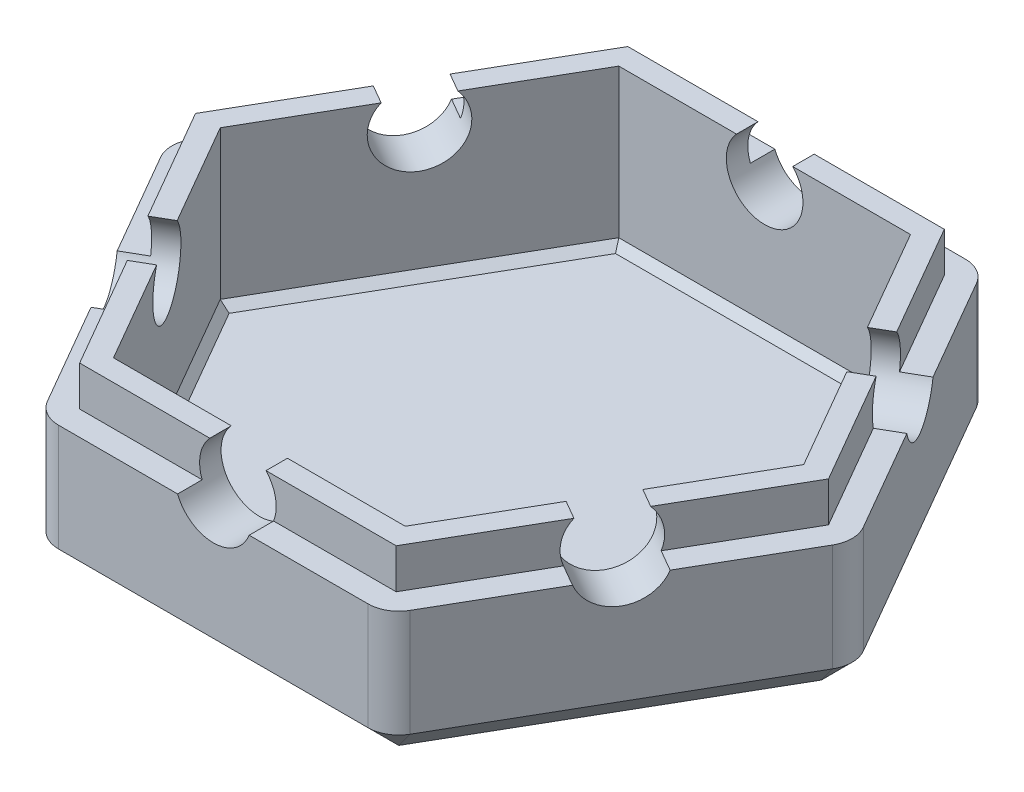
from build123d import *

# Parameters (mm, degrees)
BOSS_EXTRUDE1_START = -3.7
BOSS_EXTRUDE1_DEPTH = 10
CUT_EXTRUDE1_DEPTH  = 8.6
BOSS_EXTRUDE2_DEPTH = 1.6
FILLET1_R           = 2
CUT_EXTRUDE4_START  = -1
CUT_EXTRUDE4_DEPTH  = 1
CUT_EXTRUDE3_REACH  = 48.892
SKETCH4_R           = 2.5
CIRPATTERN1_COUNT   = 6
CHAMFER1_SIZE       = 0.5
CHAMFER2_SIZE       = 2


with BuildPart() as part:
    # Sketch1 → Boss-Extrude1 (new body)
    with BuildSketch(Plane(origin=(0, 0, 0), x_dir=(1, 0, 0), z_dir=(0, 1, 0)).offset(BOSS_EXTRUDE1_START)):
        Polygon((22.5, 0), (11.25, 19.485571585), (-11.25, 19.485571585), (-22.5, 0), (-11.25, -19.485571585), (11.25, -19.485571585), align=None)
    extrude(amount=-BOSS_EXTRUDE1_DEPTH)

    # Sketch2 → Cut-Extrude1 (cut)
    with BuildSketch(Plane(origin=(0, -3.7, 0), x_dir=(1, 0, 0), z_dir=(0, 1, 0))):
        Polygon((9.517949192, -16.485571585), (19.035898385, 0), (9.517949192, 16.485571585), (-9.517949192, 16.485571585), (-19.035898385, 0), (-9.517949192, -16.485571585), align=None)
    extrude(amount=-CUT_EXTRUDE1_DEPTH, mode=Mode.SUBTRACT)

    # Sketch3 → Boss-Extrude2 (add)
    with BuildSketch(Plane(origin=(0, -3.7, 0), x_dir=(1, 0, 0), z_dir=(0, 1, 0))):
        Polygon((10.326239569, -17.885571585), (20.652479139, 0), (10.326239569, 17.885571585), (-10.326239569, 17.885571585), (-20.652479139, 0), (-10.326239569, -17.885571585), align=None)
        Polygon((-9.517949192, -16.485571585), (9.517949192, -16.485571585), (19.035898385, 0), (9.517949192, 16.485571585), (-9.517949192, 16.485571585), (-19.035898385, 0), align=None, mode=Mode.SUBTRACT)
    extrude(amount=BOSS_EXTRUDE2_DEPTH)

    # Fillet1
    fillet1_edges = [part.edges().sort_by_distance(p)[0] for p in [
        (22.5, -8.7, 0),
        (11.25, -8.7, 19.485571585),
        (-11.25, -8.7, 19.485571585),
        (-22.5, -8.7, 0),
        (-11.25, -8.7, -19.485571585),
        (11.25, -8.7, -19.485571585),
    ]]
    fillet(fillet1_edges, radius=FILLET1_R)

    # Sketch6 → Cut-Extrude4 (cut)
    with BuildSketch(Plane(origin=(0, -3.7, 0), x_dir=(1, 0, 0), z_dir=(0, 1, 0)).offset(CUT_EXTRUDE4_START)):
        with BuildLine():
            Line((11.827350269, -18.485571585), (21.922649731, -1))
            ThreePointArc((21.922649731, -1), (22.190598923, 0), (21.922649731, 1))
            Line((21.922649731, 1), (11.827350269, 18.485571585))
            ThreePointArc((11.827350269, 18.485571585), (11.095299462, 19.217622393), (10.095299462, 19.485571585))
            Line((10.095299462, 19.485571585), (-10.095299462, 19.485571585))
            ThreePointArc((-10.095299462, 19.485571585), (-11.095299462, 19.217622393), (-11.827350269, 18.485571585))
            Line((-11.827350269, 18.485571585), (-21.922649731, 1))
            ThreePointArc((-21.922649731, 1), (-22.190598923, 0), (-21.922649731, -1))
            Line((-21.922649731, -1), (-11.827350269, -18.485571585))
            ThreePointArc((-11.827350269, -18.485571585), (-11.095299462, -19.217622393), (-10.095299462, -19.485571585))
            Line((-10.095299462, -19.485571585), (10.095299462, -19.485571585))
            ThreePointArc((10.095299462, -19.485571585), (11.095299462, -19.217622393), (11.827350269, -18.485571585))
        make_face()
        Polygon((10.326239569, -17.885571585), (20.652479139, 0), (10.326239569, 17.885571585), (-10.326239569, 17.885571585), (-20.652479139, 0), (-10.326239569, -17.885571585), align=None, mode=Mode.SUBTRACT)
    extrude(amount=CUT_EXTRUDE4_DEPTH, mode=Mode.SUBTRACT)

    # Sketch4 → Cut-Extrude3 (cut, up to next)
    with BuildSketch(Plane(origin=(0, 0, -19.485571585), x_dir=(-1, 0, 0), z_dir=(0, 0, -1)), mode=Mode.PRIVATE) as cut_extrude3_sk1:
        with Locations((0, -3.8)):
            Circle(SKETCH4_R)
    cut_extrude3_tool1 = extrude(cut_extrude3_sk1.sketch, amount=-CUT_EXTRUDE3_REACH, mode=Mode.PRIVATE) & part.part
    cut_extrude3 = cut_extrude3_tool1.solids().sort_by_distance((0, -3.8, -19.485572))[0]
    add(cut_extrude3, mode=Mode.SUBTRACT)

    # CirPattern1: Cut-Extrude3 ×6 about axis
    cirpattern1_axis = Axis((0, -12.18, 0), (0, 1, 0))
    for i in range(1, CIRPATTERN1_COUNT):
        add(cut_extrude3.rotate(cirpattern1_axis, i * 360 / CIRPATTERN1_COUNT), mode=Mode.SUBTRACT)

    # Chamfer1
    chamfer1_edges = [part.edges().sort_by_distance(p)[0] for p in [
        (-14.276923789, -12.3, 8.242785793),
        (-14.276923789, -12.3, -8.242785793),
        (0, -12.3, -16.485571585),
        (14.276923789, -12.3, -8.242785793),
        (14.276923789, -12.3, 8.242785793),
        (0, -12.3, 16.485571585),
    ]]
    chamfer(chamfer1_edges, length=CHAMFER1_SIZE)

    # Chamfer2
    chamfer2_edges = [part.edges().sort_by_distance(p)[0] for p in [
        (0, -13.7, 19.485571585),
        (11.095299462, -13.7, 19.217622393),
        (-11.095299462, -13.7, 19.217622393),
        (16.875, -13.7, 9.742785793),
        (-16.875, -13.7, 9.742785793),
        (22.190598923, -13.7, 0),
        (-22.190598923, -13.7, 0),
        (16.875, -13.7, -9.742785793),
        (-16.875, -13.7, -9.742785793),
        (11.095299462, -13.7, -19.217622393),
        (-11.095299462, -13.7, -19.217622393),
        (0, -13.7, -19.485571585),
    ]]
    chamfer(chamfer2_edges, length=CHAMFER2_SIZE)


solid = part.part
